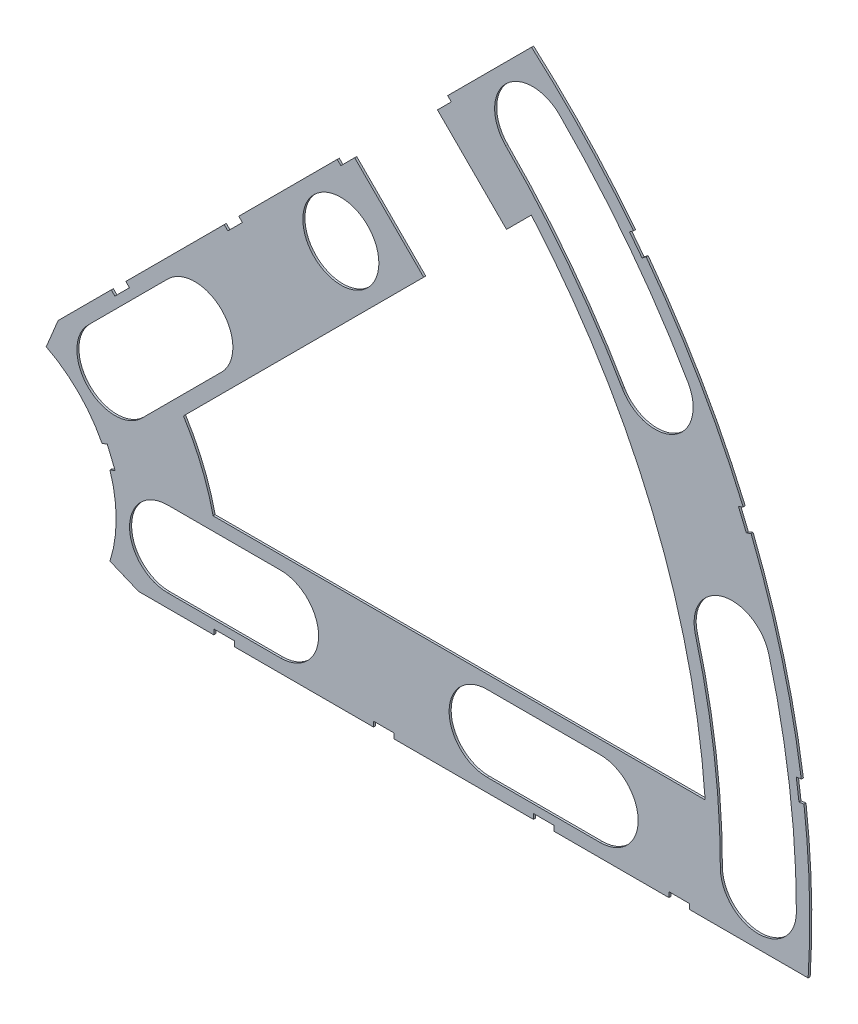
from build123d import *

# Parameters (mm, degrees)
BOSS_EXTRUDE1_DEPTH = 0.254
SKETCH2_R           = 4.699
CUT_EXTRUDE1_DEPTH  = 1.254
SKETCH3_W           = 2.54
SKETCH3_H           = 0.635
CUT_EXTRUDE2_DEPTH  = 1.254
CUT_EXTRUDE4_DEPTH  = 1.254
CUT_EXTRUDE5_DEPTH  = 1.254


with BuildPart() as part:
    # Sketch1 → Boss-Extrude1 (new body)
    with BuildSketch(Plane.XY):
        with BuildLine():
            Line((67.21146711, 76.191723231), (8.696654013, 17.676910134))
            Line((8.696654013, 17.676910134), (7.228954972, 14.133571205))
            ThreePointArc((7.228954972, 14.133571205), (14.666587579, 6.075099489), (15.105587123, -4.88230096))
            Line((15.105587123, -4.88230096), (18.648926052, -6.35))
            Line((18.648926052, -6.35), (101.401368334, -6.35))
            ThreePointArc((101.401368334, -6.35), (93.866160503, 38.880636728), (67.21146711, 76.191723231))
        make_face()
        with BuildLine():
            Line((88.672924278, 6.35), (27.86051193, 6.35))
            ThreePointArc((27.86051193, 6.35), (26.399857642, 10.93517908), (24.190484974, 15.210228852))
            Line((24.190484974, 15.210228852), (67.191354125, 58.211098004))
            ThreePointArc((67.191354125, 58.211098004), (82.13289044, 34.020557137), (88.672924278, 6.35))
        make_face(mode=Mode.SUBTRACT)
    extrude(amount=BOSS_EXTRUDE1_DEPTH)

    # Sketch2 → Cut-Extrude1 (cut, through all)
    with BuildSketch(Plane.XY.offset(0.254)):
        with Locations((22.225, 0)):
            Circle(SKETCH2_R)
        with Locations((36.195, 0)):
            Circle(SKETCH2_R)
        with Locations((61.722, 0)):
            Circle(SKETCH2_R)
        with Locations((75.692, 0)):
            Circle(SKETCH2_R)
        with Locations((95.25, 0)):
            Circle(SKETCH2_R)
        with Locations((15.715448212, 15.715448212)):
            Circle(SKETCH2_R)
        with Locations((25.593729945, 25.593729945)):
            Circle(SKETCH2_R)
        with Locations((43.644044748, 43.644044748)):
            Circle(SKETCH2_R)
        with Locations((53.522326482, 53.522326482)):
            Circle(SKETCH2_R)
        with Locations((92.004434954, 24.652514046)):
            Circle(SKETCH2_R)
        with Locations((82.48891971, 47.625)):
            Circle(SKETCH2_R)
        with Locations((67.351920908, 67.351920908)):
            Circle(SKETCH2_R)
    extrude(amount=-CUT_EXTRUDE1_DEPTH, mode=Mode.SUBTRACT)

    # Sketch3 → Cut-Extrude2 (cut, through all)
    with BuildSketch(Plane.XY.offset(0.254)):
        Polygon((15.266435406, 24.246691527), (17.06248663, 26.042742751), (17.511499436, 25.593729945), (15.715448212, 23.797678721), align=None)
        Polygon((44.991083167, 53.971339288), (43.195031942, 52.175288063), (43.644044748, 51.726275257), (45.440095973, 53.522326482), align=None)
        with Locations((29.21, -6.0325)):
            Rectangle(SKETCH3_W, SKETCH3_H)
        with Locations((68.707, -6.0325)):
            Rectangle(SKETCH3_W, SKETCH3_H)
        Polygon((29.230733674, 38.210989795), (31.026784898, 40.007041019), (31.475797704, 39.558028213), (29.67974648, 37.761976989), align=None)
        Polygon((56.845021246, 65.825277367), (55.048970022, 64.029226143), (55.497982828, 63.580213337), (57.294034052, 65.376264561), align=None)
        with Locations((48.9585, -6.0325)):
            Rectangle(SKETCH3_W, SKETCH3_H)
        with Locations((85.471, -6.0325)):
            Rectangle(SKETCH3_W, SKETCH3_H)
        Polygon((99.935462164, 14.437711971), (100.266998693, 11.919442024), (101.526133667, 12.085210288), (101.194597138, 14.603480236), align=None)
        Polygon((93.765504959, 37.464305742), (94.938831965, 37.950313702), (93.966816047, 40.296967714), (92.793489041, 39.810959755), align=None)
        Polygon((79.327792988, 62.471156422), (80.874047017, 60.456038938), (81.88160576, 61.229165953), (80.33535173, 63.244283437), align=None)
        Polygon((13.593916116, 7.005422516), (14.565932035, 4.658768503), (15.739259041, 5.144776462), (14.767243123, 7.491430475), align=None)
    extrude(amount=-CUT_EXTRUDE2_DEPTH, mode=Mode.SUBTRACT)

    # Sketch6 → Cut-Extrude4 (cut, through all)
    with BuildSketch(Plane.XY.offset(0.254)):
        with BuildLine():
            Line((12.392753447, 19.038142977), (22.27103518, 28.91642471))
            ThreePointArc((22.27103518, 28.91642471), (28.91642471, 28.91642471), (28.91642471, 22.27103518))
            Line((28.91642471, 22.27103518), (19.038142977, 12.392753447))
            ThreePointArc((19.038142977, 12.392753447), (12.392753447, 12.392753447), (12.392753447, 19.038142977))
        make_face()
        with BuildLine():
            Line((22.225, 4.699), (36.195, 4.699))
            ThreePointArc((36.195, 4.699), (40.894, 0), (36.195, -4.699))
            Line((36.195, -4.699), (22.225, -4.699))
            ThreePointArc((22.225, -4.699), (17.526, 0), (22.225, 4.699))
        make_face()
        with BuildLine():
            Line((61.722, 4.699), (75.692, 4.699))
            ThreePointArc((75.692, 4.699), (80.391, 0), (75.692, -4.699))
            Line((75.692, -4.699), (61.722, -4.699))
            ThreePointArc((61.722, -4.699), (57.023, 0), (61.722, 4.699))
        make_face()
        with BuildLine():
            ThreePointArc((99.949, 0), (99.093922449, 13.045962386), (96.543320412, 25.868704739))
            ThreePointArc((96.543320412, 25.868704739), (90.788244261, 29.191399504), (87.465549496, 23.436323353))
            ThreePointArc((87.465549496, 23.436323353), (89.776323642, 11.819277232), (90.551, 0))
            ThreePointArc((90.551, 0), (95.25, -4.699), (99.949, 0))
        make_face()
        with BuildLine():
            ThreePointArc((86.558373083, 49.9745), (79.294873009, 60.845096068), (70.674615673, 70.674615673))
            ThreePointArc((70.674615673, 70.674615673), (64.029226143, 70.674615673), (64.029226143, 64.029226143))
            ThreePointArc((64.029226143, 64.029226143), (71.838938317, 55.123956158), (78.419466338, 45.2755))
            ThreePointArc((78.419466338, 45.2755), (84.83841971, 43.555546628), (86.558373083, 49.9745))
        make_face()
    extrude(amount=-CUT_EXTRUDE4_DEPTH, mode=Mode.SUBTRACT)

    # Sketch5 → Cut-Extrude5 (cut, through all)
    with BuildSketch(Plane.XY.offset(0.254)):
        Polygon((53.881536726, 44.901280605), (64.119028704, 55.138772583), (55.138772583, 64.119028704), (44.901280605, 53.881536726), align=None)
    extrude(amount=-CUT_EXTRUDE5_DEPTH, mode=Mode.SUBTRACT)


solid = part.part
